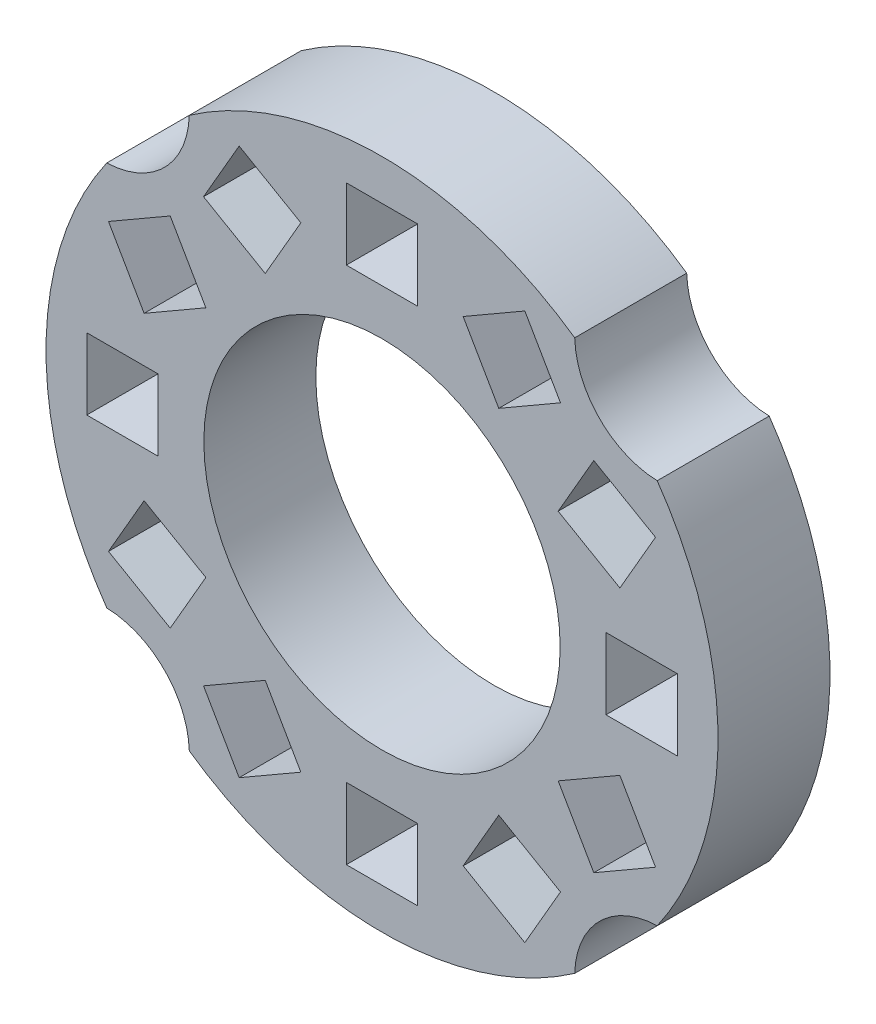
from build123d import *

# Parameters (mm, degrees)
SKETCH1_R            = 33
SKETCH1_R_2          = 17.5
SKETCH1_W            = 7
SKETCH1_H            = 7
BOSS_EXTRUDE1_DEPTH  = 11
CUT_EXTRUDE1_START   = -12
CUT_EXTRUDE1_DEPTH   = 13
MIRROR2_START        = -12
MIRROR2_COPY_1_DEPTH = 13


with BuildPart() as part:
    # Sketch1 → Boss-Extrude1 (new body)
    with BuildSketch(Plane.XY):
        Circle(SKETCH1_R)
        Circle(SKETCH1_R_2, mode=Mode.SUBTRACT)
        Polygon((17.302558883, 11.468911087), (20.802558883, 17.531088913), (26.86473671, 14.031088913), (23.36473671, 7.968911087), align=None, mode=Mode.SUBTRACT)
        with Locations((25.5, 0)):
            Rectangle(SKETCH1_W, SKETCH1_H, mode=Mode.SUBTRACT)
        Polygon((7.968911087, 23.36473671), (14.031088913, 26.86473671), (17.531088913, 20.802558883), (11.468911087, 17.302558883), align=None, mode=Mode.SUBTRACT)
        with Locations((0, 25.5)):
            Rectangle(SKETCH1_W, SKETCH1_H, mode=Mode.SUBTRACT)
        with Locations((-25.5, 0)):
            Rectangle(SKETCH1_W, SKETCH1_H, mode=Mode.SUBTRACT)
        Polygon((-23.36473671, 7.968911087), (-26.86473671, 14.031088913), (-20.802558883, 17.531088913), (-17.302558883, 11.468911087), align=None, mode=Mode.SUBTRACT)
        Polygon((-11.468911087, 17.302558883), (-17.531088913, 20.802558883), (-14.031088913, 26.86473671), (-7.968911087, 23.36473671), align=None, mode=Mode.SUBTRACT)
        Polygon((23.36473671, -7.968911087), (26.86473671, -14.031088913), (20.802558883, -17.531088913), (17.302558883, -11.468911087), align=None, mode=Mode.SUBTRACT)
        Polygon((11.468911087, -17.302558883), (17.531088913, -20.802558883), (14.031088913, -26.86473671), (7.968911087, -23.36473671), align=None, mode=Mode.SUBTRACT)
        with Locations((0, -25.5)):
            Rectangle(SKETCH1_W, SKETCH1_H, mode=Mode.SUBTRACT)
        Polygon((-7.968911087, -23.36473671), (-11.468911087, -17.302558883), (-17.531088913, -20.802558883), (-14.031088913, -26.86473671), align=None, mode=Mode.SUBTRACT)
        Polygon((-17.302558883, -11.468911087), (-23.36473671, -7.968911087), (-26.86473671, -14.031088913), (-20.802558883, -17.531088913), align=None, mode=Mode.SUBTRACT)
    extrude(amount=BOSS_EXTRUDE1_DEPTH)

    # Sketch2 → Cut-Extrude1 (cut)
    with BuildSketch(Plane.XY.offset(11).offset(CUT_EXTRUDE1_START)):
        with BuildLine():
            Line((-195.710732602, 14.035729655), (-27.032017462, 18.9280224))
            ThreePointArc((-27.032017462, 18.9280224), (-21.370045373, 21.370045373), (-18.9280224, 27.032017462))
            Line((-18.9280224, 27.032017462), (-14.035729655, 195.710732602))
            Line((-14.035729655, 195.710732602), (-252.683769537, 434.358772484))
            Line((-252.683769537, 434.358772484), (-434.358772484, 252.683769537))
            Line((-434.358772484, 252.683769537), (-195.710732602, 14.035729655))
        make_face()
    cut_extrude1 = extrude(amount=CUT_EXTRUDE1_DEPTH, mode=Mode.SUBTRACT)

    # Mirror1: Cut-Extrude1 across plane
    add(cut_extrude1.mirror(Plane(origin=(0, 0, 0), x_dir=(0, 0, 1), z_dir=(1, 0, 0))), mode=Mode.SUBTRACT)

    # Mirror2: Cut-Extrude1 across plane
    add(cut_extrude1.mirror(Plane.ZX), mode=Mode.SUBTRACT)

    # Mirror2 copy 1 sketch → Mirror2 copy 1 (cut)
    with BuildSketch(Plane(origin=(0, 0, 11), x_dir=(-1, 0, 0), z_dir=(0, 0, 1)).offset(MIRROR2_START)):
        with BuildLine():
            Line((-195.710732602, 14.035729655), (-27.032017462, 18.9280224))
            ThreePointArc((-27.032017462, 18.9280224), (-21.370045373, 21.370045373), (-18.9280224, 27.032017462))
            Line((-18.9280224, 27.032017462), (-14.035729655, 195.710732602))
            Line((-14.035729655, 195.710732602), (-252.683769537, 434.358772484))
            Line((-252.683769537, 434.358772484), (-434.358772484, 252.683769537))
            Line((-434.358772484, 252.683769537), (-195.710732602, 14.035729655))
        make_face()
    extrude(amount=MIRROR2_COPY_1_DEPTH, mode=Mode.SUBTRACT)


solid = part.part
